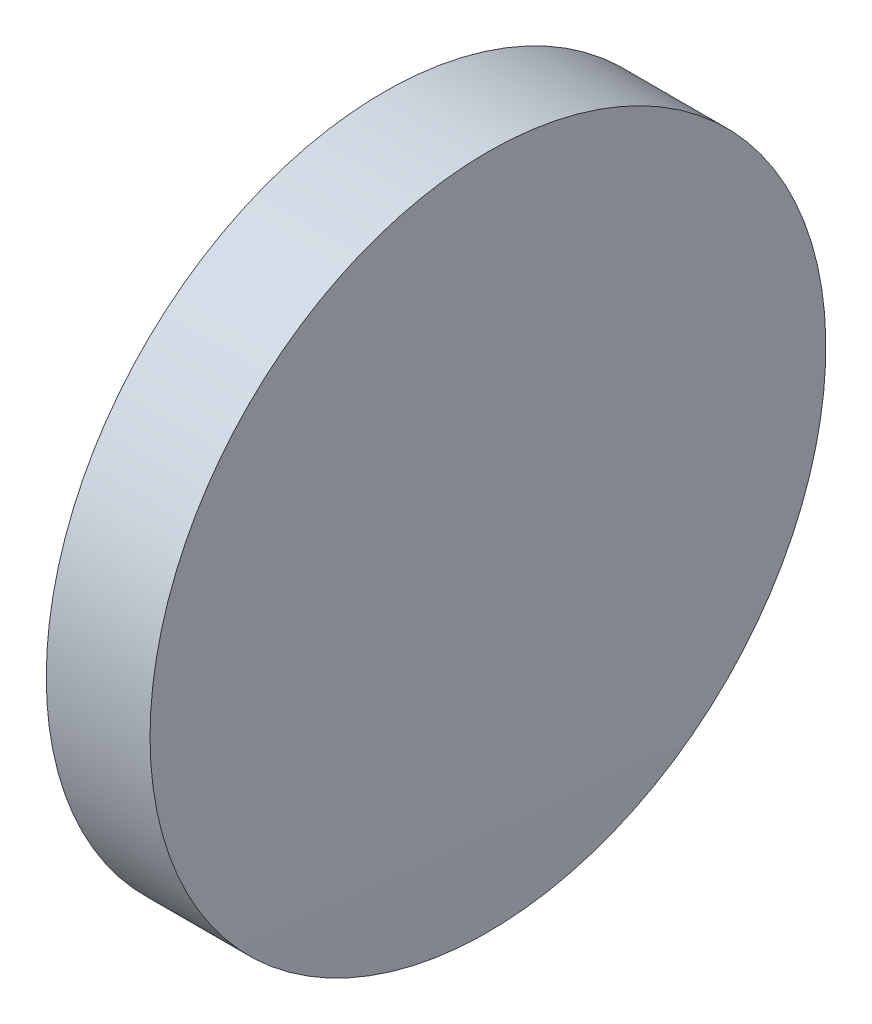
from build123d import *


with BuildPart() as part:
    # 草图1 → 旋转1 (revolve)
    with BuildSketch(Plane.XY):
        with BuildLine():
            Line((115.764555476, 65.233554926), (115.764555476, 77.933554926))
            Line((115.764555476, 77.933554926), (119.664555476, 77.933554926))
            ThreePointArc((119.664555476, 77.933554926), (119.739555089, 71.583751774), (119.764555476, 65.233554926))
            Line((119.764555476, 65.233554926), (115.764555476, 65.233554926))
        make_face()
    revolve(axis=Axis((110.165373228, 65.233554926, 0), (1, 0, 0)))


solid = part.part
